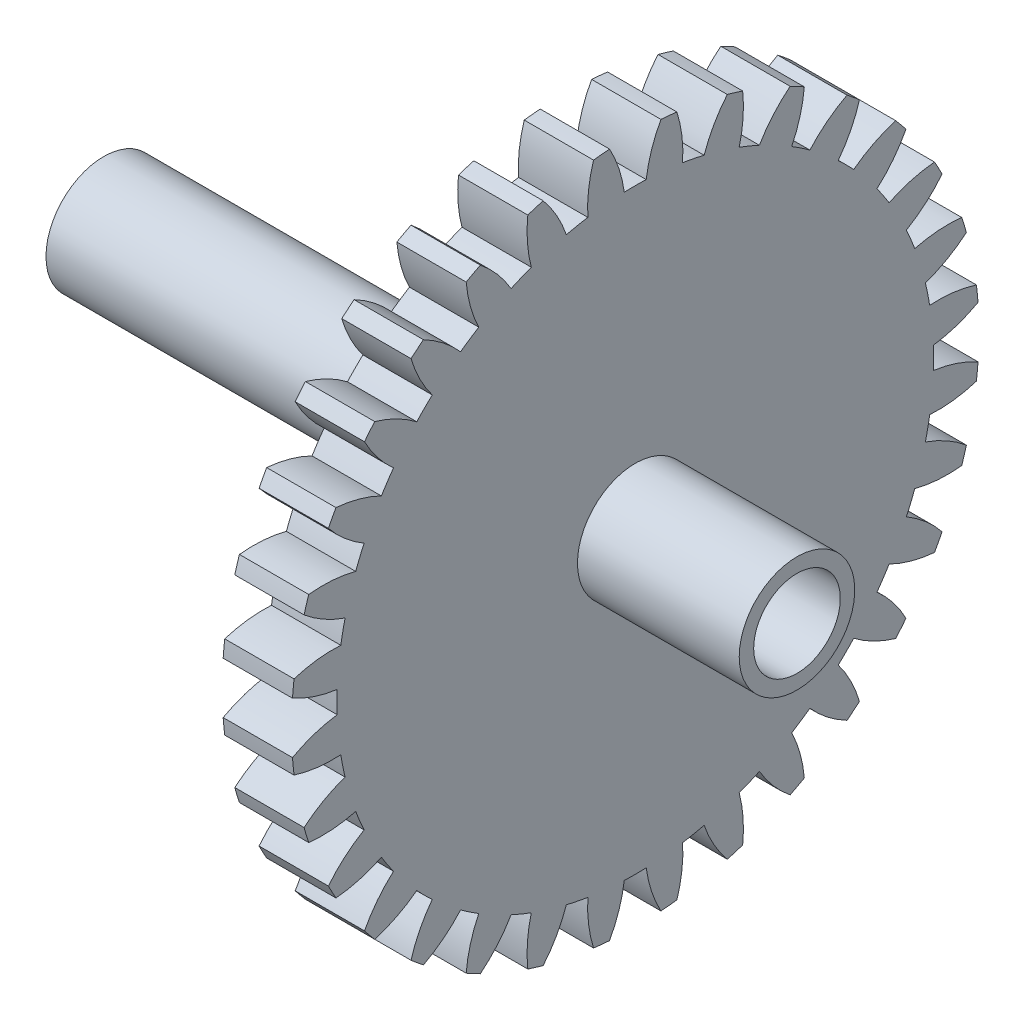
from build123d import *

# Parameters (mm, degrees)
BASPROSKE_W              = 6
BASPROSKE_H              = 29.75
TOOTHCUT_DEPTH           = 43.498529386
TEETHCUTS_COUNT          = 32
TEETHCUTS_ANGLE          = 348.75
BORSKE_R                 = 0.4
BORE_DEPTH               = 50.0000508
SKETCH1_R                = 5
SKETCH1_R_2              = 3.75
BOSS_EXTRUDE1_DEPTH      = 40
BOSS_EXTRUDE1_DEPTH_BACK = 20
SKETCH2_R                = 3.75
CUT_EXTRUDE1_DEPTH       = 10
SKETCH3_R                = 1.725
CUT_EXTRUDE2_DEPTH       = 2.5


with BuildPart() as part:
    # BasProSke → Base-Revolve (revolve)
    with BuildSketch(Plane(origin=(0, 0, 0), x_dir=(1, 0, 0), z_dir=(0, 1, 0)), mode=Mode.PRIVATE) as base_revolve_sk:
        with Locations((3, 14.875)):
            Rectangle(BASPROSKE_W, BASPROSKE_H)
    revolve(base_revolve_sk.sketch.rotate(Axis((-10, 0, 0), (1, 0, 0)), 180), axis=Axis((-10, 0, 0), (1, 0, 0)))

    # TooCutSke → ToothCut (cut, through all)
    with BuildSketch(Plane(origin=(0, 0, 0), x_dir=(0, 0, -1), z_dir=(1, 0, 0))):
        with BuildLine():
            ThreePointArc((0.948063121, 25.794082821), (0, 25.8115), (-0.948063121, 25.794082821))
            ThreePointArc((-0.948063121, 25.794082821), (-1.412588604, 27.80222237), (-2.237243361, 29.691230815))
            ThreePointArc((-2.237243361, 29.691230815), (0, 29.7754), (2.237243361, 29.691230815))
            ThreePointArc((2.237243361, 29.691230815), (1.412588604, 27.80222237), (0.948063121, 25.794082821))
        make_face()
    toothcut = extrude(amount=TOOTHCUT_DEPTH, mode=Mode.SUBTRACT)

    # TeethCuts: ToothCut ×32 about axis
    teethcuts_axis = Axis((-10, 0, 0), (1, 0, 0))
    for i in range(1, TEETHCUTS_COUNT):
        add(toothcut.rotate(teethcuts_axis, i * TEETHCUTS_ANGLE / (TEETHCUTS_COUNT - 1)), mode=Mode.SUBTRACT)

    # BorSke → Bore (cut, symmetric)
    with BuildSketch(Plane(origin=(0, 0, 0), x_dir=(0, 0, -1), z_dir=(1, 0, 0))):
        with Locations(Location((0, 0, 0), (0, 0, 180))):
            Circle(BORSKE_R)
    extrude(amount=BORE_DEPTH, both=True, mode=Mode.SUBTRACT)

    # Sketch1 → Boss-Extrude1 (add, two sides)
    with BuildSketch(Plane.ZY) as boss_extrude1_sk:
        Circle(SKETCH1_R)
        Circle(SKETCH1_R_2, mode=Mode.SUBTRACT)
    extrude(amount=BOSS_EXTRUDE1_DEPTH)
    extrude(boss_extrude1_sk.sketch, amount=-BOSS_EXTRUDE1_DEPTH_BACK)

    # Sketch2 → Cut-Extrude1 (cut)
    with BuildSketch(Plane.ZY):
        Circle(SKETCH2_R)
    extrude(amount=-CUT_EXTRUDE1_DEPTH, mode=Mode.SUBTRACT)

    # Sketch3 → Cut-Extrude2 (cut)
    with BuildSketch(Plane.ZY):
        with Locations((-24.271444902, 2.501392084)):
            Circle(SKETCH3_R)
    extrude(amount=-CUT_EXTRUDE2_DEPTH, mode=Mode.SUBTRACT)


solid = part.part
